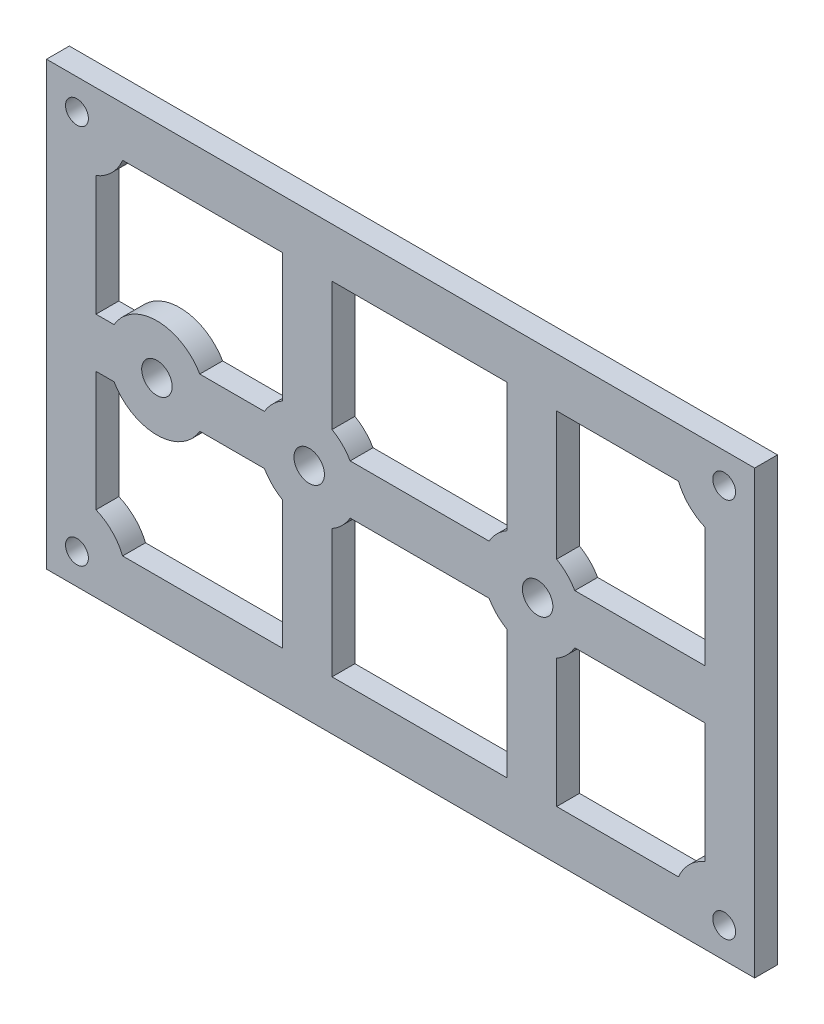
from build123d import *

# Parameters (mm, degrees)
SKETCH1_W               = 93
SKETCH1_H               = 58
BOSS_EXTRUDE1_DEPTH     = 3
SKETCH2_R               = 1.5
CUT_EXTRUDE2_DEPTH      = 3
CUT_EXTRUDE3_DEPTH      = 10
CUT_EXTRUDE3_DEPTH_BACK = 10
SKETCH6_W               = 23
SKETCH6_H               = 45
CUT_EXTRUDE4_DEPTH      = 10
SKETCH7_W               = 93
SKETCH7_H               = 6.5
BOSS_EXTRUDE2_DEPTH     = 3
SKETCH8_R               = 6.5
SKETCH8_W               = 6.5
SKETCH8_H               = 6.5
BOSS_EXTRUDE3_DEPTH     = 3
SKETCH9_R               = 2
CUT_EXTRUDE6_DEPTH      = 4
SKETCH12_R              = 6.5
SKETCH12_R_2            = 2
BOSS_EXTRUDE5_DEPTH     = 3
SKETCH14_R              = 2
CUT_EXTRUDE7_DEPTH      = 10


with BuildPart() as part:
    # Sketch1 → Boss-Extrude1 (new body)
    with BuildSketch(Plane.XY):
        Rectangle(SKETCH1_W, SKETCH1_H)
    extrude(amount=BOSS_EXTRUDE1_DEPTH)

    # Sketch2 → Cut-Extrude2 (cut)
    with BuildSketch(Plane.XY.offset(3)):
        with BuildLine():
            ThreePointArc((-42.5, 26.5), (-43.560660172, 26.060660172), (-44, 25))
            Line((-44, 25), (-42.5, 25))
            Line((-42.5, 25), (-42.5, 26.5))
        make_face()
        with BuildLine():
            Line((-42.5, 25), (-44, 25))
            ThreePointArc((-44, 25), (-42.5, 23.5), (-41, 25))
            ThreePointArc((-41, 25), (-41.439339828, 26.060660172), (-42.5, 26.5))
            Line((-42.5, 26.5), (-42.5, 25))
        make_face()
        with Locations((-42.5, -25)):
            Circle(SKETCH2_R)
        with Locations((42.5, -25)):
            Circle(SKETCH2_R)
        with Locations((42.5, 25)):
            Circle(SKETCH2_R)
    extrude(amount=-CUT_EXTRUDE2_DEPTH, mode=Mode.SUBTRACT)

    # Sketch5 → Cut-Extrude3 (cut, two sides)
    with BuildSketch(Plane.XY.offset(3)) as cut_extrude3_sk:
        with BuildLine():
            ThreePointArc((-36.5, 22.5), (-37.903805922, 20.403805922), (-40, 19))
            Line((-40, 19), (-40, -19))
            ThreePointArc((-40, -19), (-37.903805922, -20.403805922), (-36.5, -22.5))
            Line((-36.5, -22.5), (-15.5, -22.5))
            Line((-15.5, -22.5), (-15.5, 22.5))
            Line((-15.5, 22.5), (-36.5, 22.5))
        make_face()
        with BuildLine():
            Line((20.5, -22.5), (36.5, -22.5))
            ThreePointArc((36.5, -22.5), (37.903805922, -20.403805922), (40, -19))
            Line((40, -19), (40, 19))
            ThreePointArc((40, 19), (37.903805922, 20.403805922), (36.5, 22.5))
            Line((36.5, 22.5), (20.5, 22.5))
            Line((20.5, 22.5), (20.5, -22.5))
        make_face()
    extrude(amount=CUT_EXTRUDE3_DEPTH, mode=Mode.SUBTRACT)
    extrude(cut_extrude3_sk.sketch, amount=-CUT_EXTRUDE3_DEPTH_BACK, mode=Mode.SUBTRACT)

    # Sketch6 → Cut-Extrude4 (cut)
    with BuildSketch(Plane.XY.offset(3)):
        with Locations((2.5, 0)):
            Rectangle(SKETCH6_W, SKETCH6_H)
    extrude(amount=-CUT_EXTRUDE4_DEPTH, mode=Mode.SUBTRACT)

    # Sketch7 → Boss-Extrude2 (add, through all)
    with BuildSketch(Plane.XY.offset(3)):
        Rectangle(SKETCH7_W, SKETCH7_H)
    extrude(amount=-BOSS_EXTRUDE2_DEPTH)

    # Sketch8 → Boss-Extrude3 (add, through all)
    with BuildSketch(Plane.XY.offset(3)):
        with Locations((-12.25, 0)):
            Circle(SKETCH8_R)
        with Locations((-12.25, 0)):
            Rectangle(SKETCH8_W, SKETCH8_H, mode=Mode.SUBTRACT)
        with Locations((17.25, 0)):
            Circle(SKETCH8_R)
        with Locations((17.25, 0)):
            Rectangle(SKETCH8_W, SKETCH8_H, mode=Mode.SUBTRACT)
    extrude(amount=-BOSS_EXTRUDE3_DEPTH)

    # Sketch9 → Cut-Extrude6 (cut, through all)
    with BuildSketch(Plane.XY.offset(3)):
        with Locations((-12.000998453, 0)):
            Circle(SKETCH9_R)
        with Locations((17.999001547, 0)):
            Circle(SKETCH9_R)
    extrude(amount=-CUT_EXTRUDE6_DEPTH, mode=Mode.SUBTRACT)

    # Sketch12 → Boss-Extrude5 (add, through all)
    with BuildSketch(Plane.XY.offset(3)):
        with Locations((-32, 0)):
            Circle(SKETCH12_R)
        with Locations((-32, 0)):
            Circle(SKETCH12_R_2, mode=Mode.SUBTRACT)
    extrude(amount=-BOSS_EXTRUDE5_DEPTH)

    # Sketch14 → Cut-Extrude7 (cut)
    with BuildSketch(Plane.XY.offset(3)):
        with Locations((-32.000998453, 0)):
            Circle(SKETCH14_R)
    extrude(amount=-CUT_EXTRUDE7_DEPTH, mode=Mode.SUBTRACT)


solid = part.part
